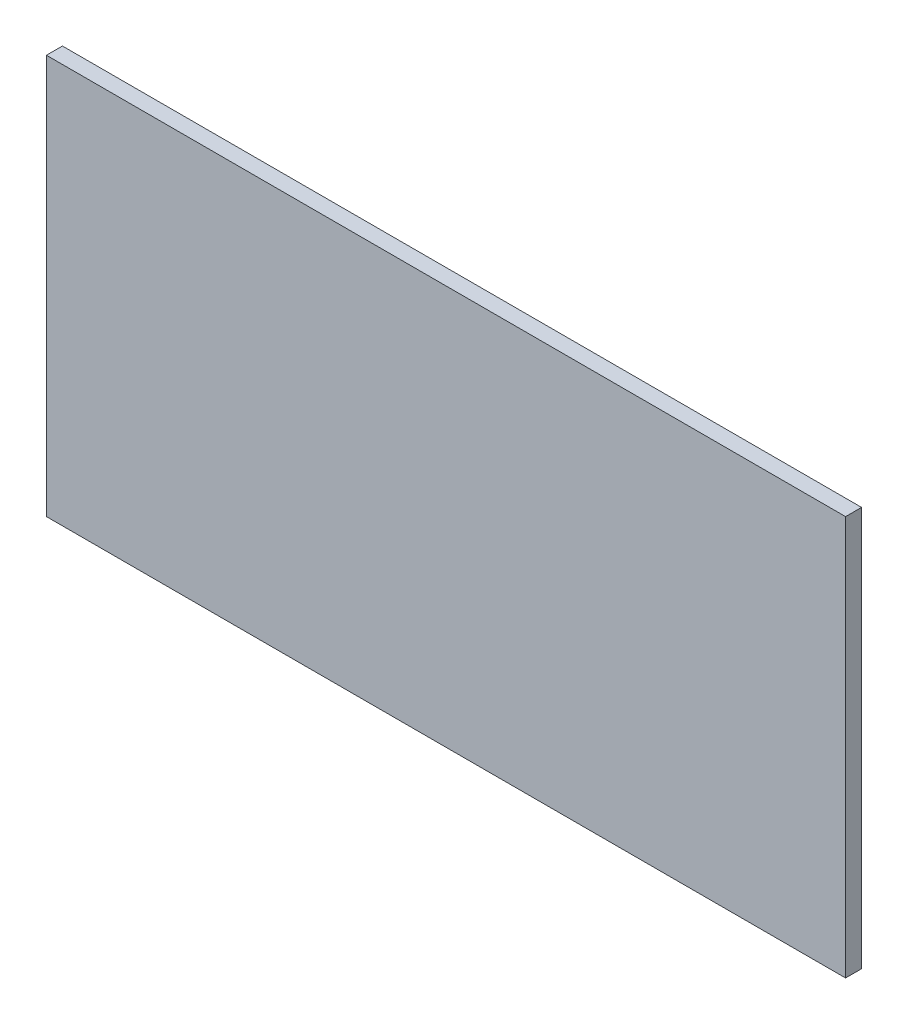
from build123d import *

# Parameters (mm, degrees)
SKETCH1_W           = 1000
SKETCH1_H           = 500
BOSS_EXTRUDE1_DEPTH = 20


with BuildPart() as part:
    # Sketch1 → Boss-Extrude1 (new body)
    with BuildSketch(Plane.XY):
        Rectangle(SKETCH1_W, SKETCH1_H)
    extrude(amount=BOSS_EXTRUDE1_DEPTH)


solid = part.part
